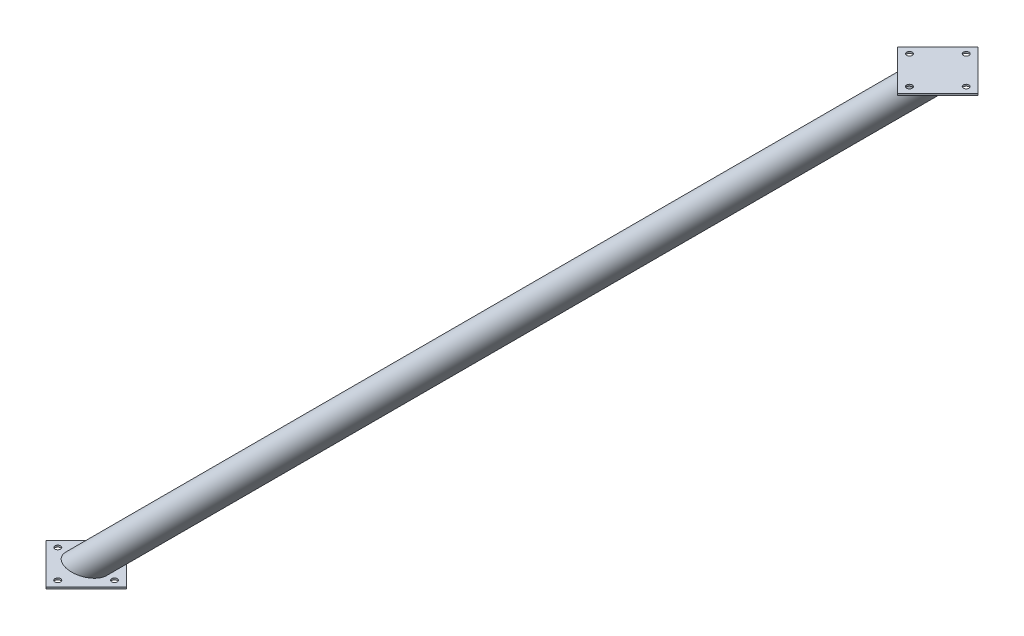
from build123d import *

# Parameters (mm, degrees)
CORTAR_EXTRUIR1_DEPTH      = 2173.26884775
CORTAR_EXTRUIR1_DEPTH_BACK = 2173.26884775
CROQUIS3_R                 = 5
SALIENTE_EXTRUIR1_DEPTH    = 3
CROQUIS9_R                 = 5
CROQUIS9_RX                = 35.921024484
CROQUIS9_RY                = 25.4
CROQUIS9_RX_2              = 33.09259736
CROQUIS9_RY_2              = 23.4
SALIENTE_EXTRUIR5_DEPTH    = 3


with BuildPart() as part:
    # Croquis1 → Revolución1 (revolve)
    with BuildSketch(Plane.XY, mode=Mode.PRIVATE) as revoluci_n1_sk:
        Polygon((1535.921024484, 1500), (0, -35.921024484), (-1.414213562, -34.506810922), (1534.506810922, 1501.414213562), align=None)
    revolve(revoluci_n1_sk.sketch.rotate(Axis((1500, 1500, 0), (-0.7071067811865476, -0.7071067811865476, 0)), 180), axis=Axis((1500, 1500, 0), (-0.7071067811865476, -0.7071067811865476, 0)))

    # Croquis2 → Cortar-Extruir1 (cut, two sides)
    with BuildSketch(Plane.XY) as cortar_extruir1_sk:
        Polygon((-35.921024484, 0), (35.921024484, 0), (0, -35.921024484), align=None)
        Polygon((1535.921024484, 1500), (1464.078975516, 1500), (1500, 1535.921024484), align=None)
    extrude(amount=CORTAR_EXTRUIR1_DEPTH, mode=Mode.SUBTRACT)
    extrude(cortar_extruir1_sk.sketch, amount=-CORTAR_EXTRUIR1_DEPTH_BACK, mode=Mode.SUBTRACT)

    # Croquis3 → Saliente-Extruir1 (add)
    with BuildSketch(Plane.XZ):
        Polygon((-70.710678119, 0), (0, 70.710678119), (70.710678119, 0), (0, -70.710678119), align=None)
        with Locations((-50, 0)):
            Circle(CROQUIS3_R, mode=Mode.SUBTRACT)
        with Locations((0, 50)):
            Circle(CROQUIS3_R, mode=Mode.SUBTRACT)
        with Locations((50, 0)):
            Circle(CROQUIS3_R, mode=Mode.SUBTRACT)
        with Locations((0, -50)):
            Circle(CROQUIS3_R, mode=Mode.SUBTRACT)
    extrude(amount=SALIENTE_EXTRUIR1_DEPTH)

    # Croquis9 → Saliente-Extruir5 (add)
    with BuildSketch(Plane(origin=(0, 1500, 0), x_dir=(1, 0, 0), z_dir=(0, 1, 0))):
        Polygon((1500, 70.710678119), (1570.710678119, 0), (1500, -70.710678119), (1429.289321881, 0), align=None)
        with Locations(Location((1450, 0, 0), (0, 0, 270))):
            Circle(CROQUIS9_R, mode=Mode.SUBTRACT)
        with Locations(Location((1500, -50, 0), (0, 0, 270))):
            Circle(CROQUIS9_R, mode=Mode.SUBTRACT)
        with Locations(Location((1550, 0, 0), (0, 0, 270))):
            Circle(CROQUIS9_R, mode=Mode.SUBTRACT)
        with Locations(Location((1500, 50, 0), (0, 0, 270))):
            Circle(CROQUIS9_R, mode=Mode.SUBTRACT)
        with Locations((1500, 0)):
            Ellipse(CROQUIS9_RX, CROQUIS9_RY, mode=Mode.SUBTRACT)
        with Locations((1500, 0)):
            Ellipse(CROQUIS9_RX, CROQUIS9_RY)
        with Locations((1500, 0)):
            Ellipse(CROQUIS9_RX_2, CROQUIS9_RY_2, mode=Mode.SUBTRACT)
        with Locations((1500, 0)):
            Ellipse(CROQUIS9_RX_2, CROQUIS9_RY_2)
    extrude(amount=SALIENTE_EXTRUIR5_DEPTH)


solid = part.part
